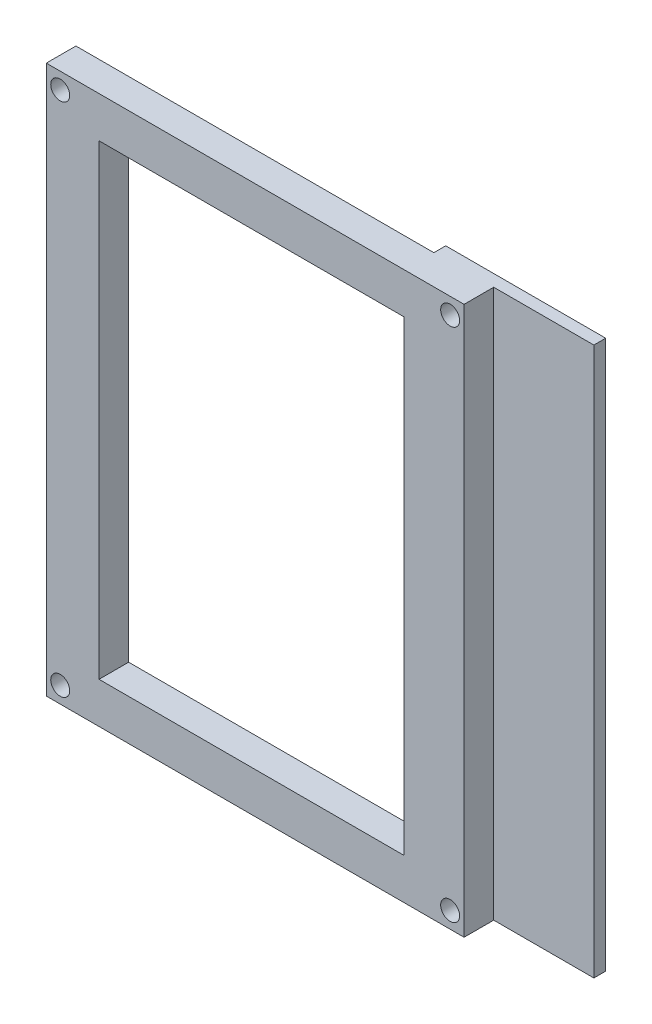
from build123d import *

# Parameters (mm, degrees)
SKETCH_1_W          = 71
SKETCH_1_H          = 93
SKETCH_1_R          = 1.6
SKETCH_1_W_2        = 51
SKETCH_1_H_2        = 78.2
EXTRUDE_1_DEPTH     = 5
SKETCH_2_W          = 71
SKETCH_2_H          = 93
SKETCH_2_W_2        = 70.5
SKETCH_2_H_2        = 92.5
CUT_EXTRUDE_1_DEPTH = 6
SKETCH_3_W          = 51.5
SKETCH_3_H          = 78.7
SKETCH_3_W_2        = 51
SKETCH_3_H_2        = 78.2
CUT_EXTRUDE_2_DEPTH = 6
SKETCH_5_W          = 27
SKETCH_5_H          = 92.5
SKETCH_5_R          = 1.6
EXTRUDE_3_DEPTH     = 2


with BuildPart() as part:
    # Эскиз1 → Бобышка-Вытянуть1 (new body)
    with BuildSketch(Plane(origin=(0, 0, 28), x_dir=(-1, 0, 0), z_dir=(0, 0, -1))):
        with Locations((-39.5, 51)):
            Rectangle(SKETCH_1_W, SKETCH_1_H)
        with Locations((-6.6, 7.5)):
            Circle(SKETCH_1_R, mode=Mode.SUBTRACT)
        with Locations((-72.4, 7.5)):
            Circle(SKETCH_1_R, mode=Mode.SUBTRACT)
        with Locations((-6.6, 94.5)):
            Circle(SKETCH_1_R, mode=Mode.SUBTRACT)
        with Locations((-72.4, 94.5)):
            Circle(SKETCH_1_R, mode=Mode.SUBTRACT)
        with Locations((-38.9, 51)):
            Rectangle(SKETCH_1_W_2, SKETCH_1_H_2, mode=Mode.SUBTRACT)
    extrude(amount=EXTRUDE_1_DEPTH)

    # Эскиз2 → Вырез-Вытянуть1 (cut, through all)
    with BuildSketch(Plane.XY.offset(28)):
        with Locations((39.5, 51)):
            Rectangle(SKETCH_2_W, SKETCH_2_H)
        with Locations((39.5, 51)):
            Rectangle(SKETCH_2_W_2, SKETCH_2_H_2, mode=Mode.SUBTRACT)
    extrude(amount=-CUT_EXTRUDE_1_DEPTH, mode=Mode.SUBTRACT)

    # Эскиз3 → Вырез-Вытянуть2 (cut, through all)
    with BuildSketch(Plane.XY.offset(28)):
        with Locations((38.9, 51)):
            Rectangle(SKETCH_3_W, SKETCH_3_H)
        with Locations((38.9, 51)):
            Rectangle(SKETCH_3_W_2, SKETCH_3_H_2, mode=Mode.SUBTRACT)
    extrude(amount=-CUT_EXTRUDE_2_DEPTH, mode=Mode.SUBTRACT)

    # Эскиз5 → Бобышка-Вытянуть3 (add)
    with BuildSketch(Plane(origin=(0, 0, 23), x_dir=(-1, 0, 0), z_dir=(0, 0, -1))):
        with Locations((-78.15, 51)):
            Rectangle(SKETCH_5_W, SKETCH_5_H)
        with Locations((-72.4, 94.5)):
            Circle(SKETCH_5_R, mode=Mode.SUBTRACT)
        with Locations((-72.4, 7.5)):
            Circle(SKETCH_5_R, mode=Mode.SUBTRACT)
    extrude(amount=EXTRUDE_3_DEPTH)


solid = part.part
